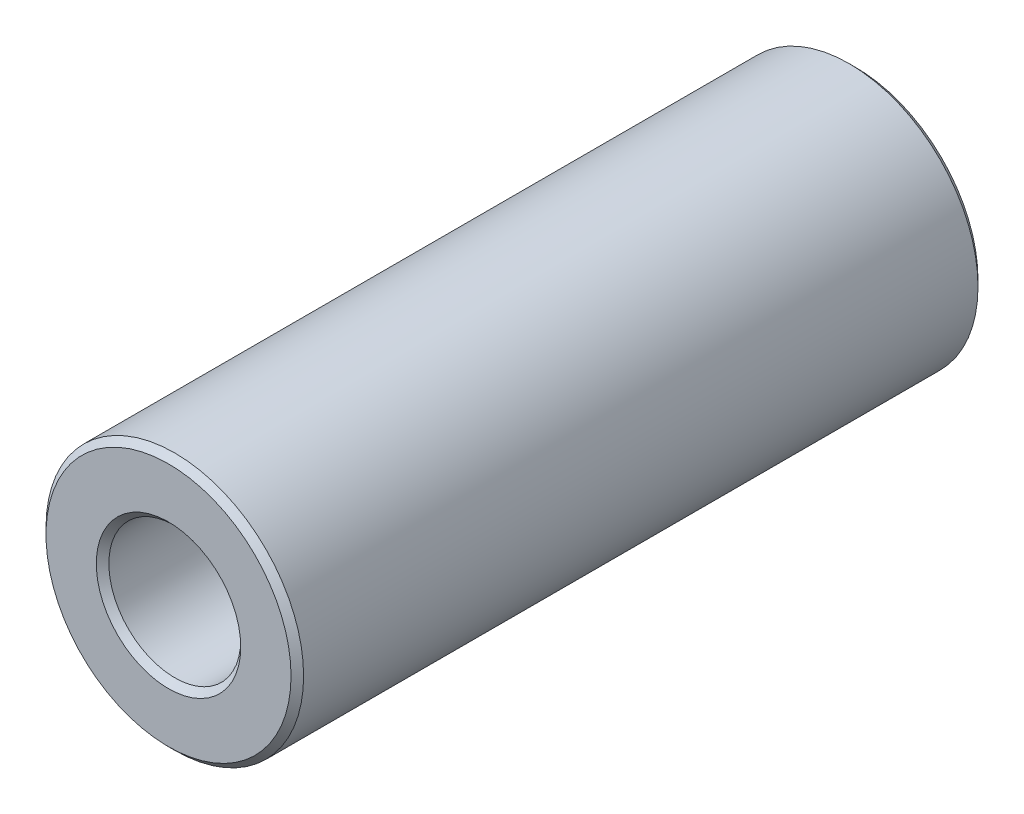
from build123d import *

# Parameters (mm, degrees)
SKETCH3_R                = 4.7625
SKETCH3_R_2              = 2.4384
BOSS_EXTRUDE1_DEPTH      = 12.7
BOSS_EXTRUDE1_DEPTH_BACK = 12.7
CHAMFER1_SIZE            = 0.23241


with BuildPart() as part:
    # Sketch3 → Boss-Extrude1 (new body, two sides)
    with BuildSketch(Plane.XY) as boss_extrude1_sk:
        Circle(SKETCH3_R)
        Circle(SKETCH3_R_2, mode=Mode.SUBTRACT)
    extrude(amount=BOSS_EXTRUDE1_DEPTH)
    extrude(boss_extrude1_sk.sketch, amount=-BOSS_EXTRUDE1_DEPTH_BACK)

    # Chamfer1
    chamfer1_edges = [part.edges().sort_by_distance(p)[0] for p in [
        (-4.7625, 0, -12.7),
        (-2.4384, 0, -12.7),
        (-4.7625, 0, 12.7),
        (-2.4384, 0, 12.7),
    ]]
    chamfer(chamfer1_edges, length=CHAMFER1_SIZE)


solid = part.part
